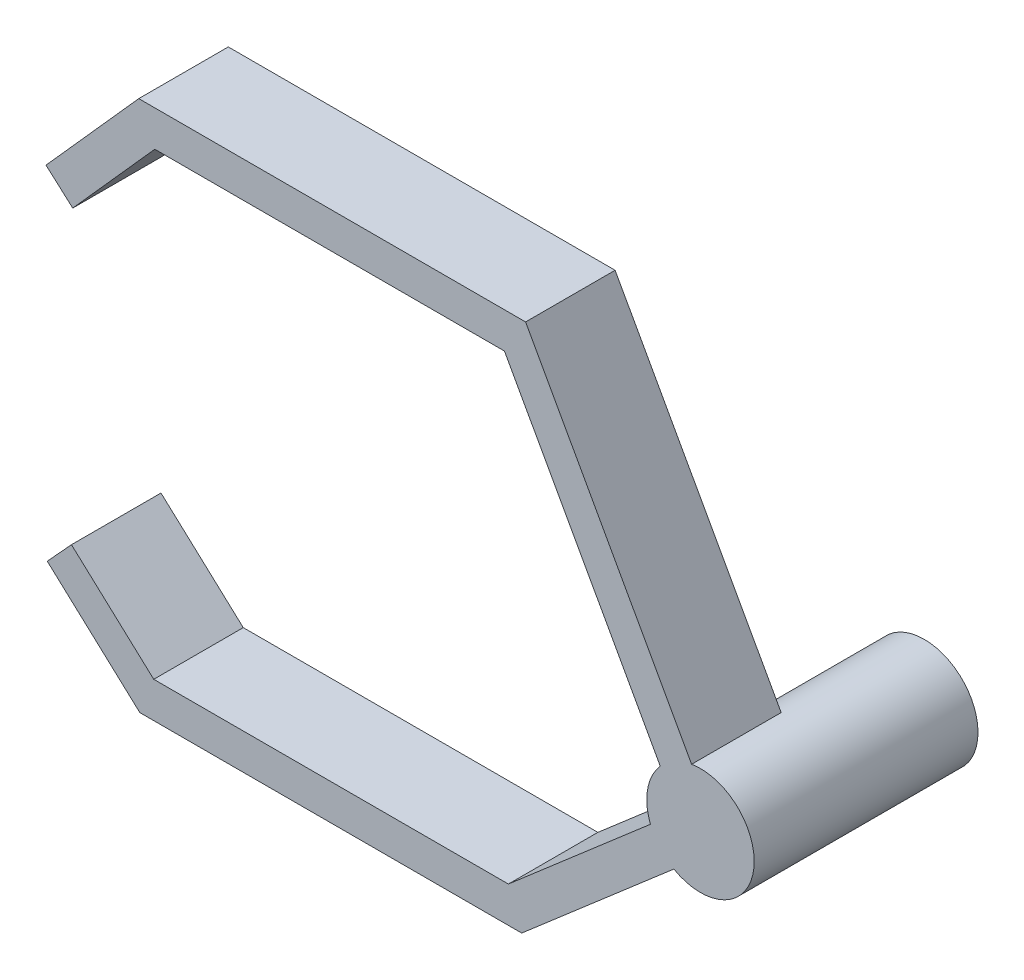
from build123d import *

# Parameters (mm, degrees)
BOSS_EXTRUDE1_DEPTH = 10
SKETCH2_R           = 6
BOSS_EXTRUDE2_DEPTH = 25


with BuildPart() as part:
    # Sketch1 → Boss-Extrude1 (new body)
    with BuildSketch(Plane.XY):
        with BuildLine():
            ThreePointArc((-4.488845509, 3.981239254), (-2.90504438, 5.249830202), (-0.988958707, 5.917935508))
            Line((-0.988958707, 5.917935508), (-19.535932482, 39.434966685))
            Line((-19.535932482, 39.434966685), (-62.745195449, 39.434966685))
            Line((-62.745195449, 39.434966685), (-73.107309745, 27.816838535))
            Line((-73.107309745, 27.816838535), (-70.122128007, 25.154379147))
            Line((-70.122128007, 25.154379147), (-60.952955338, 35.434966685))
            Line((-60.952955338, 35.434966685), (-21.894070174, 35.434966685))
            Line((-21.894070174, 35.434966685), (-4.488845509, 3.981239254))
        make_face()
        with BuildLine():
            Line((2.535804531, -0.451815201), (-2.972059937, -5.212183777))
            ThreePointArc((-2.972059937, -5.212183777), (3.013937655, -5.188080552), (6, 0))
            ThreePointArc((6, 0), (3.877257262, 4.578960157), (-0.988958707, 5.917935508))
            Line((-0.988958707, 5.917935508), (2.535804531, -0.451815201))
        make_face()
        with BuildLine():
            ThreePointArc((-5.587664835, -2.185864062), (-4.539479574, -3.923407346), (-2.972059937, -5.212183777))
            Line((-2.972059937, -5.212183777), (2.535804531, -0.451815201))
            Line((2.535804531, -0.451815201), (-0.988958707, 5.917935508))
            ThreePointArc((-0.988958707, 5.917935508), (-2.90504438, 5.249830202), (-4.488845509, 3.981239254))
            Line((-4.488845509, 3.981239254), (-2.535804531, 0.451815201))
            Line((-2.535804531, 0.451815201), (-5.587664835, -2.185864062))
        make_face()
        with BuildLine():
            Line((-72.966168133, -10.42614814), (-62.627042774, -19.903679719))
            Line((-62.627042774, -19.903679719), (-19.970484994, -19.903679719))
            Line((-19.970484994, -19.903679719), (-2.972059937, -5.212183777))
            ThreePointArc((-2.972059937, -5.212183777), (-4.539479574, -3.923407346), (-5.587664835, -2.185864062))
            Line((-5.587664835, -2.185864062), (-21.459517662, -15.903679719))
            Line((-21.459517662, -15.903679719), (-61.071108012, -15.903679719))
            Line((-61.071108012, -15.903679719), (-70.263269619, -7.477531579))
            Line((-70.263269619, -7.477531579), (-72.966168133, -10.42614814))
        make_face()
    extrude(amount=BOSS_EXTRUDE1_DEPTH)

    # Sketch2 → Boss-Extrude2 (add)
    with BuildSketch(Plane.XY.offset(10)):
        Circle(SKETCH2_R)
    extrude(amount=-BOSS_EXTRUDE2_DEPTH)


solid = part.part
